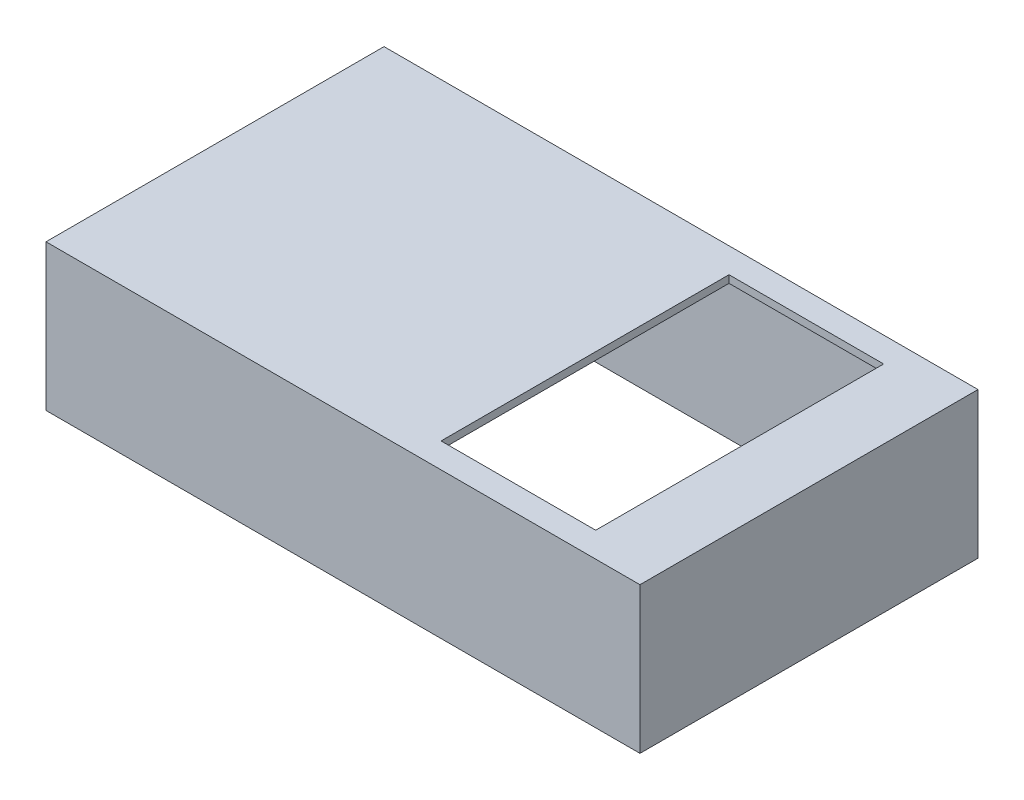
from build123d import *

# Parameters (mm, degrees)
SKETCH1_W           = 55.7
SKETCH1_H           = 31.7
BOSS_EXTRUDE1_DEPTH = 13.7
SKETCH2_W           = 14.5
SKETCH2_H           = 27
CUT_EXTRUDE1_DEPTH  = 13.7
SKETCH3_W           = 51.7
SKETCH3_H           = 27.7
CUT_EXTRUDE2_DEPTH  = 13


with BuildPart() as part:
    # Sketch1 → Boss-Extrude1 (new body)
    with BuildSketch(Plane(origin=(0, 0, 0), x_dir=(1, 0, 0), z_dir=(0, 1, 0))):
        with Locations((27.85, 15.85)):
            Rectangle(SKETCH1_W, SKETCH1_H)
    extrude(amount=BOSS_EXTRUDE1_DEPTH)

    # Sketch2 → Cut-Extrude1 (cut)
    with BuildSketch(Plane(origin=(0, 13.7, 0), x_dir=(1, 0, 0), z_dir=(0, 1, 0))):
        with Locations((41.95, 15.85)):
            Rectangle(SKETCH2_W, SKETCH2_H)
    extrude(amount=-CUT_EXTRUDE1_DEPTH, mode=Mode.SUBTRACT)

    # Sketch3 → Cut-Extrude2 (cut)
    with BuildSketch(Plane.XZ):
        with Locations((27.85, -15.85)):
            Rectangle(SKETCH3_W, SKETCH3_H)
    extrude(amount=-CUT_EXTRUDE2_DEPTH, mode=Mode.SUBTRACT)


solid = part.part
